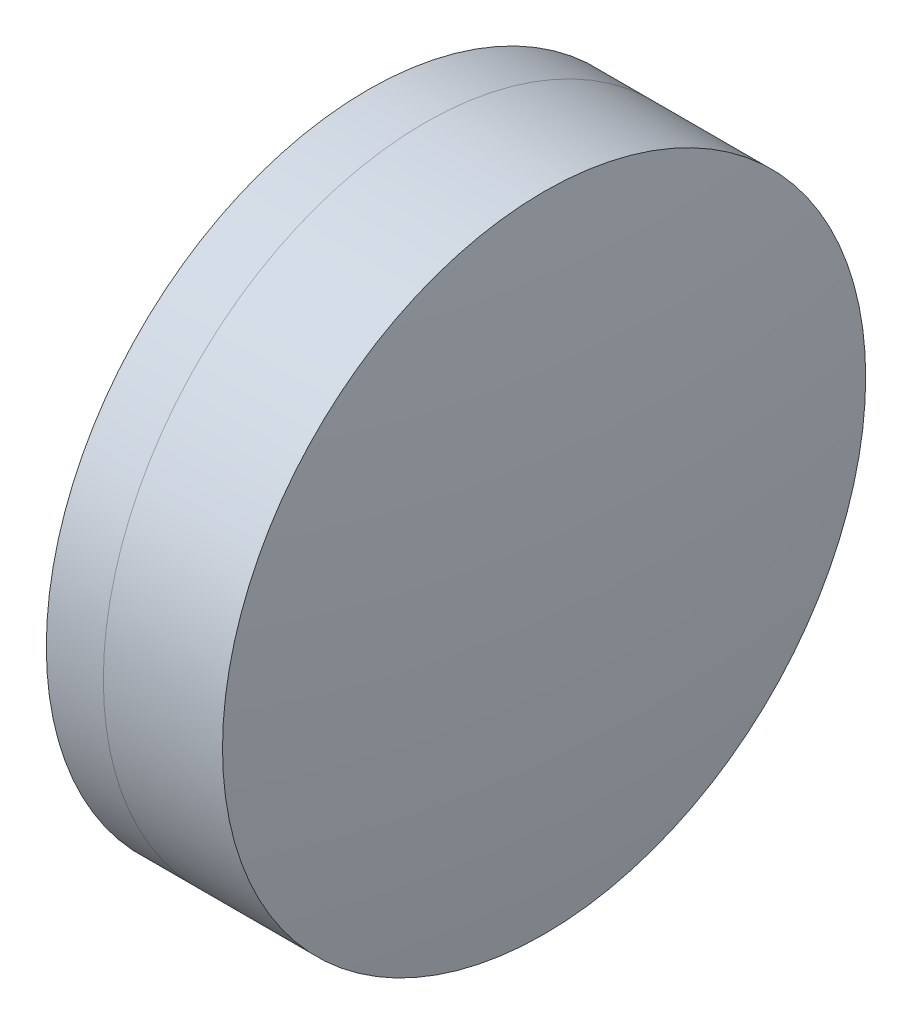
from build123d import *


with BuildPart() as part:
    # 草图1 one side → 旋转1 (revolve)
    with BuildSketch(Plane(origin=(0, 0, 0), x_dir=(1, 0, 0), z_dir=(0, 1, 0)), mode=Mode.PRIVATE) as revolve_1_sk:
        with BuildLine():
            ThreePointArc((31.106085439, 12.5), (28.980266168, 6.40999389), (28.259668974, 0))
            Line((28.259668974, 0), (37.159668974, 0))
            ThreePointArc((37.159668974, 0), (36.17885848, 6.537807458), (33.322781509, 12.5))
            Line((33.322781509, 12.5), (31.106085439, 12.5))
        make_face()
    revolve(revolve_1_sk.sketch.rotate(Axis((-9.702612178, 0, 0), (1, 0, 0)), 180), axis=Axis((-9.702612178, 0, 0), (1, 0, 0)))  # turned: the seam where the file's is


with BuildPart() as body_2:
    # 草图2 one side → 旋转3 (revolve)
    with BuildSketch(Plane(origin=(0, 0, 0), x_dir=(1, 0, 0), z_dir=(0, 1, 0)), mode=Mode.PRIVATE) as revolve_3_sk:
        with BuildLine():
            Line((37.955067003, 12.5), (33.322781509, 12.5))
            ThreePointArc((33.322781509, 12.5), (36.17885848, 6.537807458), (37.159668974, 0))
            Line((37.159668974, 0), (38.759668974, 0))
            ThreePointArc((38.759668974, 0), (38.558310557, 6.262934303), (37.955067003, 12.5))
        make_face()
    revolve(revolve_3_sk.sketch.rotate(Axis((-0.551919993, 0, 0), (1, 0, 0)), 180), axis=Axis((-0.551919993, 0, 0), (1, 0, 0)))  # turned: the seam where the file's is


solid = Compound([part.part, body_2.part])
